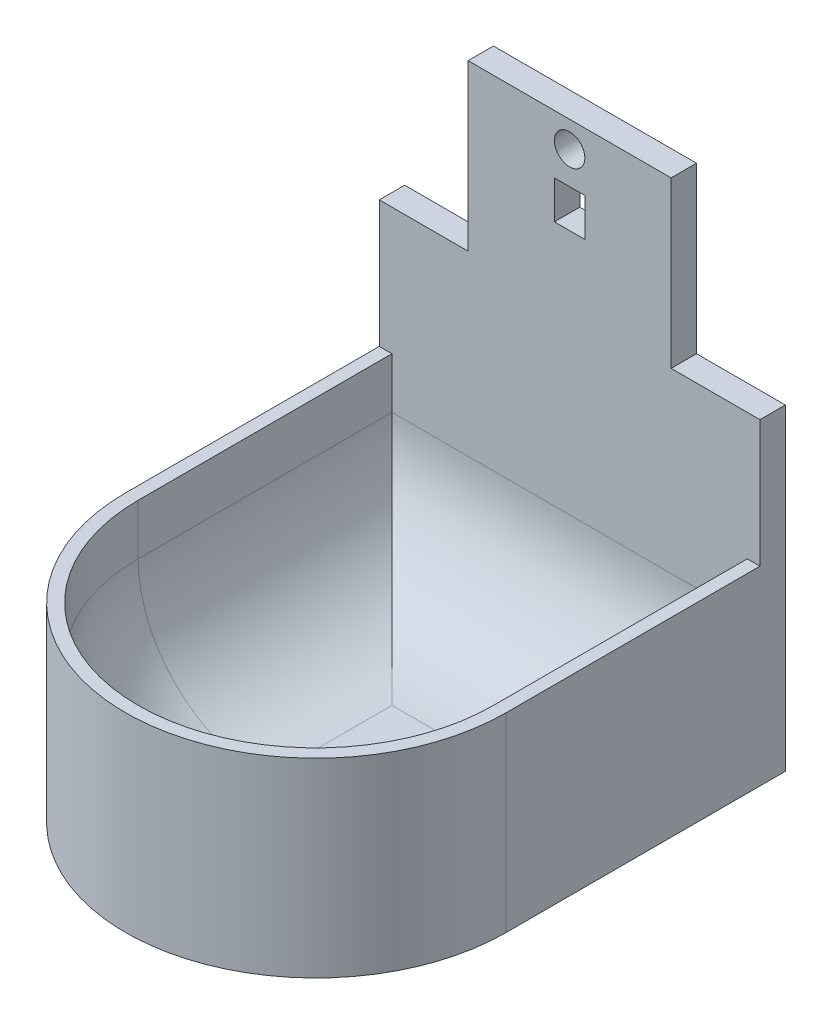
from build123d import *

# Parameters (mm, degrees)
BOSS_EXTRUDE1_DEPTH = 1.27
BOSS_EXTRUDE3_DEPTH = 17.78
SKETCH5_W           = 38.1
SKETCH5_H           = 19.05
BOSS_EXTRUDE4_DEPTH = 2.54
FILLET1_R           = 12.7
BOSS_EXTRUDE5_DEPTH = 2.54
CUT_EXTRUDE6_REACH  = 48.99
SKETCH12_R          = 1.524
SKETCH12_W          = 3.048
SKETCH12_H          = 3.81


with BuildPart() as part:
    # Sketch1 → Boss-Extrude1 (new body)
    with BuildSketch(Plane(origin=(0, 0, 0), x_dir=(1, 0, 0), z_dir=(0, 1, 0))):
        with BuildLine():
            Line((0, 0), (38.1, 0))
            Line((38.1, 0), (38.1, -25.4))
            ThreePointArc((38.1, -25.4), (19.05, -44.45), (0, -25.4))
            Line((0, -25.4), (0, 0))
        make_face()
    extrude(amount=BOSS_EXTRUDE1_DEPTH)

    # Sketch3 → Boss-Extrude3 (add)
    with BuildSketch(Plane(origin=(0, 1.27, 0), x_dir=(1, 0, 0), z_dir=(0, 1, 0))):
        with BuildLine():
            Line((0, 0), (0, -25.4))
            ThreePointArc((0, -25.4), (19.05, -44.45), (38.1, -25.4))
            Line((38.1, -25.4), (38.1, 0))
            Line((38.1, 0), (36.83, 0))
            Line((36.83, 0), (36.83, -25.4))
            ThreePointArc((36.83, -25.4), (19.05, -43.18), (1.27, -25.4))
            Line((1.27, -25.4), (1.27, 0))
            Line((1.27, 0), (0, 0))
        make_face()
    extrude(amount=BOSS_EXTRUDE3_DEPTH)

    # Sketch5 → Boss-Extrude4 (add)
    with BuildSketch(Plane(origin=(0, 0, 0), x_dir=(-1, 0, 0), z_dir=(0, 0, -1))):
        with Locations((-19.05, 9.525)):
            Rectangle(SKETCH5_W, SKETCH5_H)
    extrude(amount=BOSS_EXTRUDE4_DEPTH)

    # Fillet1
    fillet1_edges = [part.edges().sort_by_distance(p)[0] for p in [
        (19.05, 1.27, 0),
        (36.83, 1.27, 12.7),
        (19.05, 1.27, 43.18),
        (1.27, 1.27, 12.7),
    ]]
    fillet(fillet1_edges, radius=FILLET1_R)

    # Sketch10 → Boss-Extrude5 (add)
    with BuildSketch(Plane(origin=(0, 0, -2.54), x_dir=(-1, 0, 0), z_dir=(0, 0, -1))):
        Polygon((-29.21, 31.75), (-29.21, 48.26), (-8.89, 48.26), (-8.89, 31.75), (0, 31.75), (0, 19.05), (-38.1, 19.05), (-38.1, 31.75), align=None)
    extrude(amount=-BOSS_EXTRUDE5_DEPTH)

    # Sketch12 → Cut-Extrude6 (cut, up to next)
    with BuildSketch(Plane(origin=(0, 0, -2.54), x_dir=(-1, 0, 0), z_dir=(0, 0, -1)), mode=Mode.PRIVATE) as cut_extrude6_sk1:
        with Locations((-19.05, 45.6565)):
            Circle(SKETCH12_R)
    cut_extrude6_tool1 = extrude(cut_extrude6_sk1.sketch, amount=-CUT_EXTRUDE6_REACH, mode=Mode.PRIVATE) & part.part
    add(cut_extrude6_tool1.solids().sort_by_distance((19.05, 45.6565, -2.54))[0], mode=Mode.SUBTRACT)
    # Sketch12 → Cut-Extrude6 (cut, up to next)
    with BuildSketch(Plane(origin=(0, 0, -2.54), x_dir=(-1, 0, 0), z_dir=(0, 0, -1)), mode=Mode.PRIVATE) as cut_extrude6_sk2:
        with Locations((-19.05, 40.513)):
            Rectangle(SKETCH12_W, SKETCH12_H)
    cut_extrude6_tool2 = extrude(cut_extrude6_sk2.sketch, amount=-CUT_EXTRUDE6_REACH, mode=Mode.PRIVATE) & part.part
    add(cut_extrude6_tool2.solids().sort_by_distance((19.05, 40.513, -2.54))[0], mode=Mode.SUBTRACT)


solid = part.part
